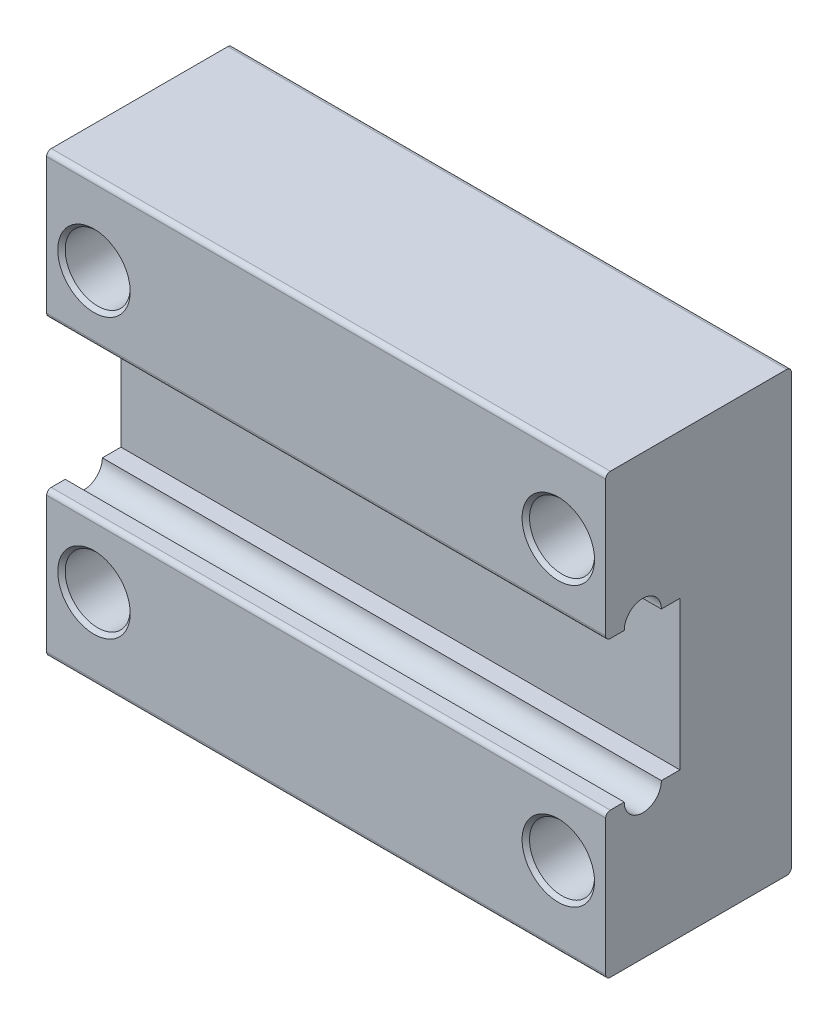
from build123d import *

# Parameters (mm, degrees)
SKETCH1_W           = 45
SKETCH1_H           = 23.6
SKETCH1_R           = 1.75
BOSS_EXTRUDE1_DEPTH = 10
SKETCH2_R           = 1
SKETCH2_W           = 4
SKETCH2_H           = 8
CUT_EXTRUDE1_DEPTH  = 46
FILLET1_R           = 0.25
CHAMFER1_SIZE       = 0.2
SKETCH3_W           = 11.00513931
SKETCH3_H           = 32.516866569
SKETCH3_W_2         = 10
SKETCH3_H_2         = 36.117344973
CUT_EXTRUDE2_DEPTH  = 10


with BuildPart() as part:
    # Sketch1 → Boss-Extrude1 (new body)
    with BuildSketch(Plane.XY):
        Rectangle(SKETCH1_W, SKETCH1_H)
        with Locations((-12.5, 7.5)):
            Circle(SKETCH1_R, mode=Mode.SUBTRACT)
        with Locations((12.5, 7.5)):
            Circle(SKETCH1_R, mode=Mode.SUBTRACT)
        with Locations((12.5, -7.5)):
            Circle(SKETCH1_R, mode=Mode.SUBTRACT)
        with Locations((-12.5, -7.5)):
            Circle(SKETCH1_R, mode=Mode.SUBTRACT)
    extrude(amount=BOSS_EXTRUDE1_DEPTH)

    # Sketch2 → Cut-Extrude1 (cut, through all)
    with BuildSketch(Plane(origin=(22.5, 0, 0), x_dir=(0, 0, -1), z_dir=(1, 0, 0))):
        with Locations((-8, 4)):
            Circle(SKETCH2_R)
        with Locations((-8, -4)):
            Circle(SKETCH2_R)
        with Locations((-8, 0)):
            Rectangle(SKETCH2_W, SKETCH2_H)
    extrude(amount=-CUT_EXTRUDE1_DEPTH, mode=Mode.SUBTRACT)

    # Fillet1
    fillet1_edges = [part.edges().sort_by_distance(p)[0] for p in [
        (22.5, -7.9, 10),
        (0, 11.8, 10),
        (22.5, 7.9, 10),
        (-22.5, -7.9, 10),
        (0, -4, 10),
        (-22.5, 7.9, 10),
        (0, 4, 10),
        (0, 11.8, 0),
        (22.5, 0, 0),
        (0, -11.8, 0),
        (-22.5, 0, 0),
        (0, -11.8, 10),
        (-22.5, 11.8, 5),
        (22.5, 11.8, 5),
        (22.5, -11.8, 5),
        (-22.5, -11.8, 5),
    ]]
    fillet(fillet1_edges, radius=FILLET1_R)

    # Chamfer1
    chamfer1_edges = [part.edges().sort_by_distance(p)[0] for p in [
        (-14.25, 7.5, 0),
        (-14.25, 7.5, 10),
        (10.75, 7.5, 0),
        (10.75, 7.5, 10),
        (10.75, -7.5, 0),
        (10.75, -7.5, 10),
        (-14.25, -7.5, 0),
        (-14.25, -7.5, 10),
    ]]
    chamfer(chamfer1_edges, length=CHAMFER1_SIZE)

    # Sketch3 → Cut-Extrude2 (cut)
    with BuildSketch(Plane(origin=(0, 0, 0), x_dir=(-1, 0, 0), z_dir=(0, 0, -1))):
        with Locations((-20.552569655, 1.232790519)):
            Rectangle(SKETCH3_W, SKETCH3_H)
        with Locations((20.05, -0.567448683)):
            Rectangle(SKETCH3_W_2, SKETCH3_H_2)
    extrude(amount=-CUT_EXTRUDE2_DEPTH, mode=Mode.SUBTRACT)


solid = part.part
